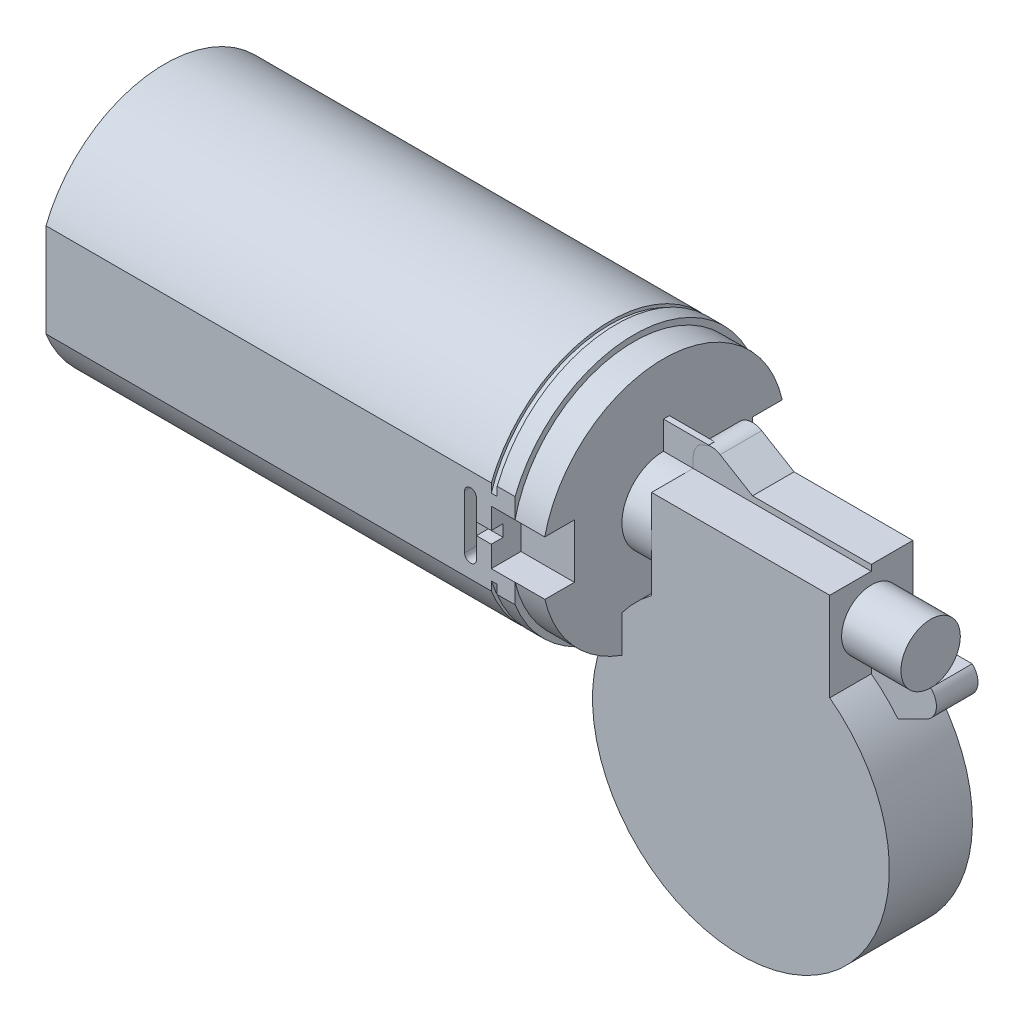
from build123d import *

# Parameters (mm, degrees)
BOSS_EXTRU_1_DEPTH      = 75
BOSS_EXTRU_2_DEPTH      = 1
BOSS_EXTRU_3_DEPTH      = 3
BOSS_EXTRU_4_DEPTH      = 5
ENL_V_START             = -9
ENL_V_MAT_EXTRU_4_DEPTH = 9
ESQUISSE6_W             = 1.343848997
ESQUISSE6_H             = 2
ENL_V_MAT_EXTRU_5_DEPTH = 2
ESQUISSE7_W             = 4.610249179
ESQUISSE7_H             = 2
ENL_V_MAT_EXTRU_7_DEPTH = 2
ESQUISSE8_R             = 7
BOSS_EXTRU_5_DEPTH      = 35
ESQUISSE9_R             = 5
BOSS_EXTRU_6_DEPTH      = 10
BOSS_EXTRU_7_DEPTH      = 14
BOSS_EXTRU_8_DEPTH      = 7
ESQUISSE11_W            = 8.454779373
ESQUISSE11_H            = 0.357592341
BOSS_EXTRU_14_DEPTH     = 1
ESQUISSE11_W_2          = 8.547038988
ESQUISSE11_H_2          = 4.701428863
BOSS_EXTRU_14_2_DEPTH   = 1
ESQUISSE13_R            = 1.5
ENL_V_MAT_EXTRU_9_DEPTH = 5
BOSS_EXTRU_19_DEPTH     = 6
BOSS_EXTRU_21_DEPTH     = 1


with BuildPart() as part:
    # Esquisse1 → Boss.-Extru.1 (new body)
    with BuildSketch(Plane(origin=(0, 0, 0), x_dir=(0, 0, -1), z_dir=(1, 0, 0))):
        with BuildLine():
            Line((-20, 7.889866919), (-20, -7.889866919))
            ThreePointArc((-20, -7.889866919), (0, -21.5), (20, -7.889866919))
            Line((20, -7.889866919), (20, 7.889866919))
            ThreePointArc((20, 7.889866919), (0, 21.5), (-20, 7.889866919))
        make_face()
    extrude(amount=BOSS_EXTRU_1_DEPTH)

    # Esquisse2 → Boss.-Extru.2 (add)
    with BuildSketch(Plane(origin=(75, 0, 0), x_dir=(0, 0, -1), z_dir=(1, 0, 0))):
        with BuildLine():
            Line((-20, 6.403124237), (-20, -6.403124237))
            ThreePointArc((-20, -6.403124237), (0, -21), (20, -6.403124237))
            Line((20, -6.403124237), (20, 6.403124237))
            ThreePointArc((20, 6.403124237), (0, 21), (-20, 6.403124237))
        make_face()
    extrude(amount=BOSS_EXTRU_2_DEPTH)

    # Esquisse3 → Boss.-Extru.3 (add)
    with BuildSketch(Plane(origin=(76, 0, 0), x_dir=(0, 0, -1), z_dir=(1, 0, 0))):
        with BuildLine():
            Line((-20, 7.889866919), (-20, -7.889866919))
            ThreePointArc((-20, -7.889866919), (0, -21.5), (20, -7.889866919))
            Line((20, -7.889866919), (20, 7.889866919))
            ThreePointArc((20, 7.889866919), (0, 21.5), (-20, 7.889866919))
        make_face()
    extrude(amount=BOSS_EXTRU_3_DEPTH)

    # Esquisse4 → Boss.-Extru.4 (add)
    with BuildSketch(Plane(origin=(79, 0, 0), x_dir=(0, 0, -1), z_dir=(1, 0, 0))):
        with BuildLine():
            Line((-20.052462527, 4.260134574), (-20, -4.5))
            ThreePointArc((-20, -4.5), (0.122767809, -20.499632389), (20.052462527, -4.260134574))
            Line((20.052462527, -4.260134574), (20.052462527, 4.260134574))
            ThreePointArc((20.052462527, 4.260134574), (0, 20.5), (-20.052462527, 4.260134574))
        make_face()
    extrude(amount=BOSS_EXTRU_4_DEPTH)

    # Esquisse5 → Enlèv. mat.-Extru.4 (cut)
    with BuildSketch(Plane(origin=(84, 0, 0), x_dir=(0, 0, -1), z_dir=(1, 0, 0)).offset(ENL_V_START)):
        Polygon((-20, 4.5), (-15, 4.5), (-15, -4.616819805), (-20, -4.616819805), (-23.835096054, -4.616819805), (-23.835096054, 4.5), align=None)
        Polygon((20, -4.616819805), (15, -4.616819805), (15, 4.5), (20, 4.5), (24.013796719, 4.5), (24.013796719, -4.616819805), align=None)
    extrude(amount=ENL_V_MAT_EXTRU_4_DEPTH, mode=Mode.SUBTRACT)

    # Esquisse6 → Enlèv. mat.-Extru.5 (cut)
    with BuildSketch(Plane.XY.offset(20)):
        with BuildLine():
            Line((72.5, -4.558409903), (72.5, 4.441590097))
            ThreePointArc((72.5, 4.441590097), (71.5, 5.441590097), (70.5, 4.441590097))
            Line((70.5, 4.441590097), (70.5, -4.558409903))
            ThreePointArc((70.5, -4.558409903), (71.5, -5.558409903), (72.5, -4.558409903))
        make_face()
        Polygon((72.5, -0.058409903), (72.5, -1.058409903), (75, -1.058409903), (75, 0.941590097), (72.5, 0.941590097), align=None)
        with Locations((75.671924499, -0.058409903)):
            Rectangle(ESQUISSE6_W, ESQUISSE6_H)
    extrude(amount=-ENL_V_MAT_EXTRU_5_DEPTH, mode=Mode.SUBTRACT)

    # Esquisse7 → Enlèv. mat.-Extru.7 (cut)
    with BuildSketch(Plane(origin=(0, 0, -20), x_dir=(-1, 0, 0), z_dir=(0, 0, -1))):
        with BuildLine():
            Line((-70.5, 4.441590097), (-70.5, -4.558409903))
            ThreePointArc((-70.5, -4.558409903), (-71.5, -5.558409903), (-72.5, -4.558409903))
            Line((-72.5, -4.558409903), (-72.5, 4.441590097))
            ThreePointArc((-72.5, 4.441590097), (-71.5, 5.441590097), (-70.5, 4.441590097))
        make_face()
        with Locations((-74.038724408, -0.058409903)):
            Rectangle(ESQUISSE7_W, ESQUISSE7_H)
    extrude(amount=-ENL_V_MAT_EXTRU_7_DEPTH, mode=Mode.SUBTRACT)

    # Esquisse8 → Boss.-Extru.5 (add)
    with BuildSketch(Plane(origin=(84, 0, 0), x_dir=(0, 0, -1), z_dir=(1, 0, 0))):
        Circle(ESQUISSE8_R)
    extrude(amount=BOSS_EXTRU_5_DEPTH)

    # Esquisse9 → Boss.-Extru.6 (add)
    with BuildSketch(Plane(origin=(119, 0, 0), x_dir=(0, 0, -1), z_dir=(1, 0, 0))):
        Circle(ESQUISSE9_R)
    extrude(amount=BOSS_EXTRU_6_DEPTH)

    # Esquisse3D1 → Boss.-Extru.7 (add)
    with BuildSketch(Plane(origin=(119, -7, 7), x_dir=(-0.9061831399952655, 0.42288546533112387, 0), z_dir=(0, 0, 1))):
        with BuildLine():
            Line((0, 0), (-0.40889541, 0.876204451))
            ThreePointArc((-0.40889541, 0.876204451), (-5.950101839, 47.985584164), (26.748554102, 13.622864171))
            Line((26.748554102, 13.622864171), (27.1854942, 12.68656396))
            Line((27.1854942, 12.68656396), (30.145692457, 6.34328198))
            Line((30.145692457, 6.34328198), (33.105890714, 0))
            Line((33.105890714, 0), (5.920396515, -12.68656396))
            Line((5.920396515, -12.68656396), (2.960198257, -6.34328198))
            Line((2.960198257, -6.34328198), (0, 0))
        make_face()
    extrude(amount=-BOSS_EXTRU_7_DEPTH)

    # Esquisse10 → Boss.-Extru.8 (add)
    with BuildSketch(Plane(origin=(0, 0, -7), x_dir=(-1, 0, 0), z_dir=(0, 0, -1))):
        with BuildLine():
            Line((-93.543487266, 11.27390764), (-99, 8))
            Line((-99, 8), (-119, 8))
            Line((-119, 8), (-119, 7))
            Line((-119, 7), (-89, 7))
            Line((-89, 7), (-89, 8.701428863))
            ThreePointArc((-89, 8.701428863), (-90.521903555, 11.312028583), (-93.543487266, 11.27390764))
        make_face()
    extrude(amount=-BOSS_EXTRU_8_DEPTH)

    # Esquisse13 → Enlèv. mat.-Extru.9 (cut)
    with BuildSketch(Plane(origin=(0, 0, -7), x_dir=(-1, 0, 0), z_dir=(0, 0, -1))):
        with Locations((-92, 8.701428863)):
            Circle(ESQUISSE13_R)
    extrude(amount=-ENL_V_MAT_EXTRU_9_DEPTH, mode=Mode.SUBTRACT)

    # Esquisse14 → Boss.-Extru.19 (add)
    with BuildSketch(Plane(origin=(0, 0, -7), x_dir=(-1, 0, 0), z_dir=(0, 0, -1))):
        with BuildLine():
            Line((-119, -7.966917626), (-119, -5))
            Line((-119, -5), (-129, -5))
            ThreePointArc((-129, -5), (-129.947341767, -7.625116181), (-128.322942162, -9.894481139))
            Line((-128.322942162, -9.894481139), (-123.510402797, -12.313464527))
            ThreePointArc((-123.510402797, -12.313464527), (-121.391871018, -9.998369292), (-119, -7.966917626))
        make_face()
        with BuildLine():
            Line((-116.735831391, -15.718647205), (-119, -5))
            Line((-119, -5), (-119, -7.966917626))
            ThreePointArc((-119, -7.966917626), (-121.391871018, -9.998369292), (-123.510402797, -12.313464527))
            Line((-123.510402797, -12.313464527), (-116.735831391, -15.718647205))
        make_face()
    extrude(amount=-BOSS_EXTRU_19_DEPTH)

    # Esquisse15 → Boss.-Extru.21 (add)
    with BuildSketch(Plane.XY.offset(-1)):
        with BuildLine():
            Line((129, -5), (119, -5))
            Line((119, -5), (119, -7.966917626))
            ThreePointArc((119, -7.966917626), (121.391871018, -9.998369292), (123.510402797, -12.313464527))
            Line((123.510402797, -12.313464527), (128.322942162, -9.894481139))
            ThreePointArc((128.322942162, -9.894481139), (129.947341767, -7.625116181), (129, -5))
        make_face()
        with BuildLine():
            Line((119, -7.966917626), (119, -5))
            Line((119, -5), (129, -5))
            Line((129, -5), (129, -4.21403801))
            Line((129, -4.21403801), (116.988858201, -4.21403801))
            Line((116.988858201, -4.21403801), (116.735831391, -15.718647205))
            Line((116.735831391, -15.718647205), (123.510402797, -12.313464527))
            ThreePointArc((123.510402797, -12.313464527), (121.391871018, -9.998369292), (119, -7.966917626))
        make_face()
    extrude(amount=BOSS_EXTRU_21_DEPTH)


with BuildPart() as body_2:
    # Esquisse11 → Boss.-Extru.14 (new body)
    with BuildSketch(Plane.XY):
        with Locations((87.363409124, 6.813235512)):
            Rectangle(ESQUISSE11_W, ESQUISSE11_H)
    extrude(amount=-BOSS_EXTRU_14_DEPTH)


with BuildPart() as body_3:
    # Esquisse11 → Boss.-Extru.14 2 (new body)
    with BuildSketch(Plane.XY):
        with Locations((87.317279316, 9.350714432)):
            Rectangle(ESQUISSE11_W_2, ESQUISSE11_H_2)
    extrude(amount=-BOSS_EXTRU_14_2_DEPTH)


solid = Compound([part.part, body_2.part, body_3.part])
